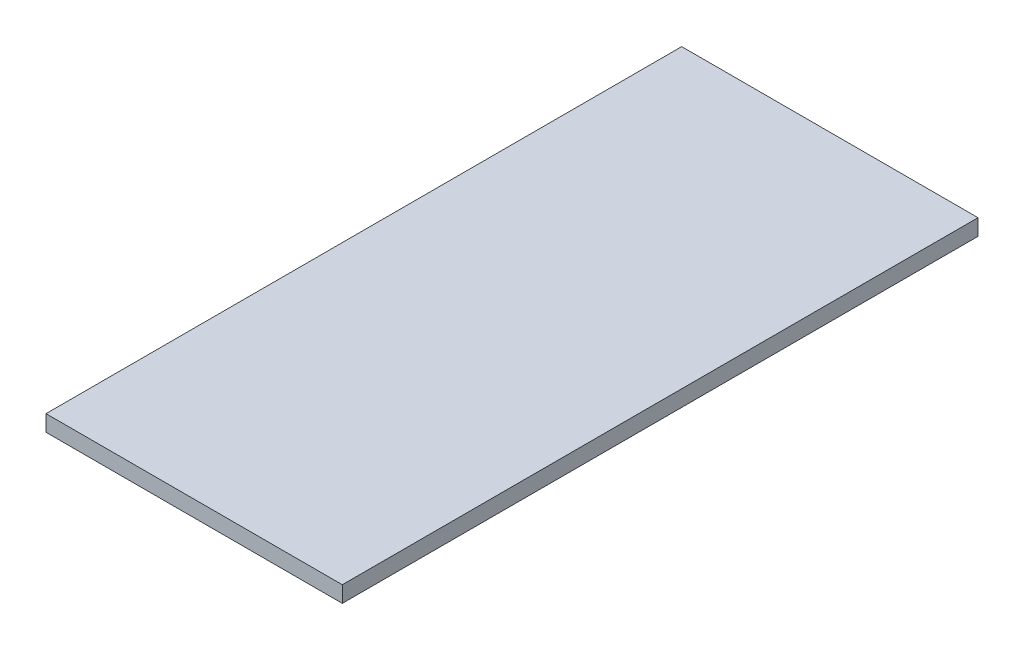
from build123d import *

# Parameters (mm, degrees)
SKETCH1_W           = 55
SKETCH1_H           = 118
BOSS_EXTRUDE1_DEPTH = 3


with BuildPart() as part:
    # Sketch1 → Boss-Extrude1 (new body)
    with BuildSketch(Plane(origin=(0, 0, 0), x_dir=(1, 0, 0), z_dir=(0, 1, 0))):
        Rectangle(SKETCH1_W, SKETCH1_H)
    extrude(amount=BOSS_EXTRUDE1_DEPTH)


solid = part.part
